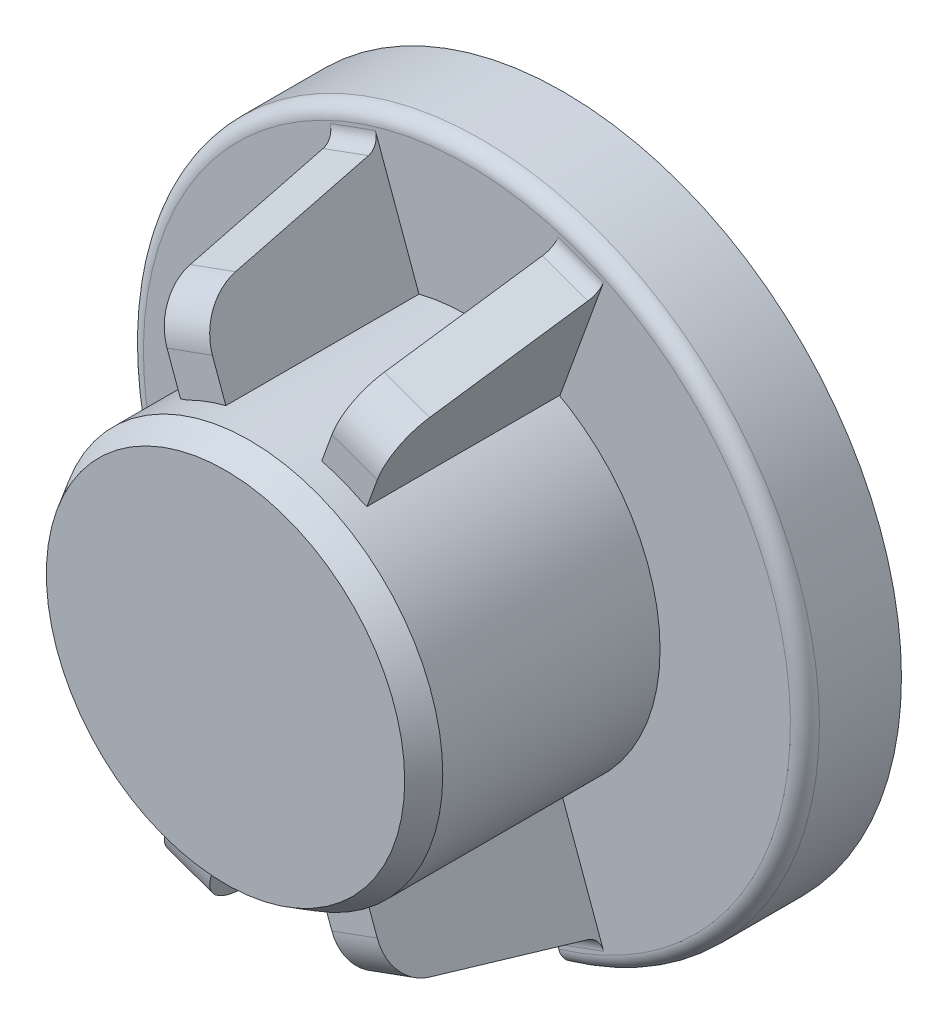
from build123d import *

# Parameters (mm, degrees)
SZKIC1_R                          = 4
DODANIE_WYCI_GNI_CIE1_DEPTH       = 6
SZKIC1_3_R                        = 7
SZKIC1_3_R_2                      = 4
DODANIE_WYCI_GNI_CIE2_DEPTH       = 2
DODANIE_WYCI_GNI_CIE3_START       = 6
SZKIC1_4_R                        = 4
DODANIE_WYCI_GNI_CIE3_DEPTH       = 1
SFAZOWANIE1_SIZE                  = 0.5
SFAZOWANIE1_SIZE2                 = 0.28867513459481364
SFAZOWANIE2_SIZE                  = 0.5
SFAZOWANIE2_SIZE2                 = 0.28867513459481364
WYCI_GNI_CIE_CIENKA_CIANKA1_DEPTH = 4
WYTNIJ_WYCI_GNI_CIE1_DEPTH        = 4
WYTNIJ_WYCI_GNI_CIE2_DEPTH        = 4
ZAOKR_GLENIE2_R                   = 1
WYTNIJ_WYCI_GNI_CIE3_START        = -4
WYTNIJ_WYCI_GNI_CIE3_DEPTH        = 4
ZAOKR_GLENIE4_R                   = 0.3
ZAOKR_GLENIE5_R                   = 0.3
ZAOKR_GLENIE2_OF_LUSTRO2_R        = 1
ZAOKR_GLENIE4_OF_LUSTRO2_R        = 0.3


with BuildPart() as part:
    # Szkic1 → Dodanie-wyci_gni_cie1 (new body)
    with BuildSketch(Plane.XY):
        Circle(SZKIC1_R)
        with BuildLine():
            Line((1.5, 2.5980762113533156), (1.5, -2.5980762113533156))
            ThreePointArc((1.4999999999999998, -2.598076211353315), (-2.999999999999999, 3.7e-16), (1.4999999999999998, 2.598076211353315))
        make_face(mode=Mode.SUBTRACT)
    extrude(amount=DODANIE_WYCI_GNI_CIE1_DEPTH)

    # Szkic1_3 → Dodanie-wyci_gni_cie2 (add)
    with BuildSketch(Plane.XY):
        Circle(SZKIC1_3_R)
        Circle(SZKIC1_3_R_2, mode=Mode.SUBTRACT)
    extrude(amount=DODANIE_WYCI_GNI_CIE2_DEPTH)

    # Szkic1_4 → Dodanie-wyci_gni_cie3 (add)
    with BuildSketch(Plane.XY.offset(DODANIE_WYCI_GNI_CIE3_START)):
        Circle(SZKIC1_4_R)
    extrude(amount=DODANIE_WYCI_GNI_CIE3_DEPTH)

    # Sfazowanie1
    sfazowanie1_edges = [part.edges().sort_by_distance(p)[0] for p in [
        (-2.999999999999999, 8.9e-16, 6),
        (1.5, 0, 6),
    ]]
    sfazowanie1_side = [part.faces().sort_by_distance(p)[0] for p in [
        (-0.5139804124502736, 6.2e-16, 6),
    ]]
    chamfer(sfazowanie1_edges, length=SFAZOWANIE1_SIZE, length2=SFAZOWANIE1_SIZE2, reference=sfazowanie1_side[0])

    # Sfazowanie2
    sfazowanie2_edges = [part.edges().sort_by_distance(p)[0] for p in [
        (-4, 4.9e-16, 7),
    ]]
    sfazowanie2_side = [part.faces().sort_by_distance(p)[0] for p in [
        (-4, 4.9e-16, 4.5),
    ]]
    chamfer(sfazowanie2_edges, length=SFAZOWANIE2_SIZE, length2=SFAZOWANIE2_SIZE2, reference=sfazowanie2_side[0])

    # Szkic3 → Wyci_gni_cie-cienka _cianka1 (add)
    with BuildSketch(Plane.XY.offset(2)):
        Polygon((0.9907558800275146, -3.8680137479259677), (1.811604224009121, -6.123276037812147), (2.751296844795029, -5.781255894486478), (1.930448500813423, -3.5259936046002984), align=None)
        Polygon((-1.930448500813423, -3.525993604600299), (-2.7512968447950286, -5.7812558944864785), (-1.81160422400912, -6.123276037812148), (-0.9907558800275145, -3.868013747925968), align=None)
    wyci_gni_cie_cienka_cianka1 = extrude(amount=WYCI_GNI_CIE_CIENKA_CIANKA1_DEPTH)

    # Szkic4 → Wytnij-wyci_gni_cie1 (cut)
    with BuildSketch(Plane(origin=(-0.5713964233589274, 0.2079712900688191, 0), x_dir=(0, 0, 1), z_dir=(-0.9396926207859082, 0.3420201433256693, 0))):
        Polygon((6, -6.373602444112237), (6, -5.623602444112237), (2, -6.373602444112238), align=None)
    wytnij_wyci_gni_cie1 = extrude(amount=-WYTNIJ_WYCI_GNI_CIE1_DEPTH, mode=Mode.SUBTRACT)

    # Szkic5 → Wytnij-wyci_gni_cie2 (cut)
    with BuildSketch(Plane(origin=(-0.36829619742698255, -0.13404885325685056, 0), x_dir=(0, 0, 1), z_dir=(-0.939692620785908, -0.3420201433256696, 0))):
        Polygon((2, -6.373602444112238), (6, -6.373602444112237), (6, -5.373602444112237), align=None)
    wytnij_wyci_gni_cie2 = extrude(amount=-WYTNIJ_WYCI_GNI_CIE2_DEPTH, mode=Mode.SUBTRACT)

    # Zaokr_glenie2
    zaokr_glenie2_edges = [part.edges().sort_by_distance(p)[0] for p in [
        (1.9394303910764068, -5.012573345363405, 6),
        (-2.0249354269078235, -5.247496500559882, 6),
    ]]
    fillet(zaokr_glenie2_edges, radius=ZAOKR_GLENIE2_R)

    # Szkic6 → Wytnij-wyci_gni_cie3 (cut)
    with BuildSketch(Plane.XY.offset(2).offset(WYTNIJ_WYCI_GNI_CIE3_START)):
        with BuildLine():
            Line((-1.8116042240091212, -6.12327603781215), (-2.0220891373099885, -6.701578584242144))
            ThreePointArc((-2.0220891373099885, -6.701578584242144), (-0.0188863375955117, -6.999974521828791), (1.985897465033318, -6.7123923647515005))
            Line((1.985897465033318, -6.7123923647515005), (1.8116042240091235, -6.12327603781215))
            Line((1.8116042240091235, -6.12327603781215), (0.9932012722690525, -3.8747324078913032))
            ThreePointArc((0.9932012722690525, -3.8747324078913032), (-9e-16, -3.999999999999983), (-0.9932012722690527, -3.874732407891303))
            Line((-0.9932012722690527, -3.874732407891303), (-1.8116042240091212, -6.12327603781215))
        make_face()
    extrude(amount=WYTNIJ_WYCI_GNI_CIE3_DEPTH, mode=Mode.SUBTRACT)

    # Zaokr_glenie4
    zaokr_glenie4_edges = [part.edges().sort_by_distance(p)[0] for p in [
        (2.281450534402075, -5.952265966149312, 2),
        (-2.281450534402074, -5.952265966149313, 2),
    ]]
    fillet(zaokr_glenie4_edges, radius=ZAOKR_GLENIE4_R)

    # Zaokr_glenie5
    zaokr_glenie5_edges = [part.edges().sort_by_distance(p)[0] for p in [
        (0.0188863375955115, 6.999974521828793, 2),
    ]]
    fillet(zaokr_glenie5_edges, radius=ZAOKR_GLENIE5_R)

    # Lustro2: Wyci_gni_cie-cienka _cianka1, Wytnij-wyci_gni_cie1, Wytnij-wyci_gni_cie2 across plane
    add(wyci_gni_cie_cienka_cianka1.mirror(Plane.ZX))
    add(wytnij_wyci_gni_cie1.mirror(Plane.ZX), mode=Mode.SUBTRACT)
    add(wytnij_wyci_gni_cie2.mirror(Plane.ZX), mode=Mode.SUBTRACT)

    # Zaokr_glenie2 of Lustro2
    zaokr_glenie2_of_lustro2_edges = [part.edges().sort_by_distance(p)[0] for p in [
        (1.9394303910764068, 5.012573345363405, 6),
        (-2.0249354269078235, 5.247496500559882, 6),
    ]]
    fillet(zaokr_glenie2_of_lustro2_edges, radius=ZAOKR_GLENIE2_OF_LUSTRO2_R)

    # Zaokr_glenie4 of Lustro2
    zaokr_glenie4_of_lustro2_edges = [part.edges().sort_by_distance(p)[0] for p in [
        (2.281450534402075, 5.952265966149312, 2),
        (-2.281450534402074, 5.952265966149313, 2),
    ]]
    fillet(zaokr_glenie4_of_lustro2_edges, radius=ZAOKR_GLENIE4_OF_LUSTRO2_R)


solid = part.part
